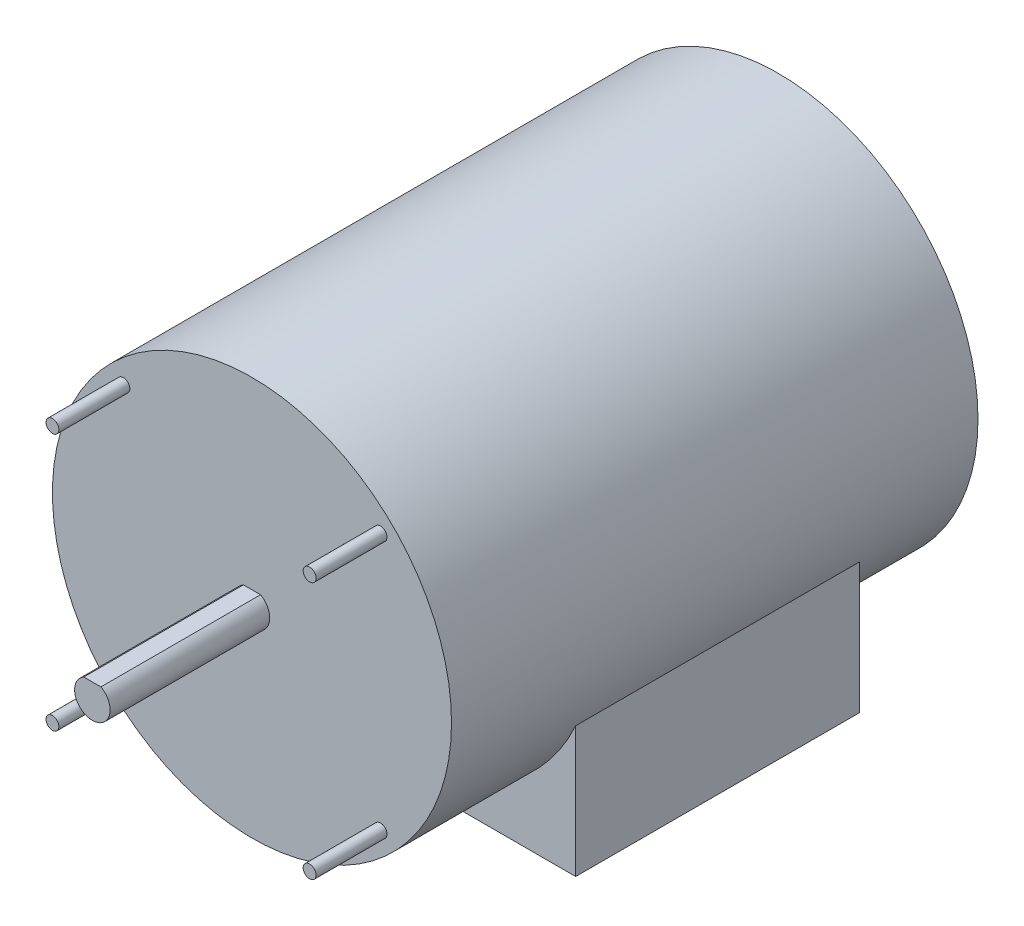
from build123d import *

# Parameters (mm, degrees)
SKETCH1_R           = 71.4375
BOSS_EXTRUDE1_DEPTH = 188.4934
SKETCH2_R           = 2.308225
BOSS_EXTRUDE2_DEPTH = 25.4
BOSS_EXTRUDE3_DEPTH = 57.15
SKETCH4_W           = 130.175
SKETCH4_H           = 101.6
SKETCH4_R           = 4.3688
BOSS_EXTRUDE4_DEPTH = 76.2


with BuildPart() as part:
    # Sketch1 → Boss-Extrude1 (new body)
    with BuildSketch(Plane.XY):
        Circle(SKETCH1_R)
    extrude(amount=BOSS_EXTRUDE1_DEPTH)

    # Sketch2 → Boss-Extrude2 (add)
    with BuildSketch(Plane.XY.offset(188.4934)):
        with Locations((-46.0375, 46.0375)):
            Circle(SKETCH2_R)
        with Locations((-46.0375, -46.0375)):
            Circle(SKETCH2_R)
        with Locations((46.0375, -46.0375)):
            Circle(SKETCH2_R)
        with Locations((46.0375, 46.0375)):
            Circle(SKETCH2_R)
    extrude(amount=BOSS_EXTRUDE2_DEPTH)

    # Sketch3 → Boss-Extrude3 (add)
    with BuildSketch(Plane.XY.offset(188.4934)):
        with BuildLine():
            Line((-3.062675504, 5.5626), (3.062675504, 5.5626))
            ThreePointArc((3.062675504, 5.5626), (0, -6.35), (-3.062675504, 5.5626))
        make_face()
    extrude(amount=BOSS_EXTRUDE3_DEPTH)

    # Sketch4 → Boss-Extrude4 (add)
    with BuildSketch(Plane(origin=(0, 0, 0), x_dir=(1, 0, 0), z_dir=(0, 1, 0))):
        with Locations((0, -86.8934)):
            Rectangle(SKETCH4_W, SKETCH4_H)
        with Locations((-53.975, -121.8184)):
            Circle(SKETCH4_R, mode=Mode.SUBTRACT)
        with Locations((53.975, -121.8184)):
            Circle(SKETCH4_R, mode=Mode.SUBTRACT)
        with Locations((-53.975, -51.9684)):
            Circle(SKETCH4_R, mode=Mode.SUBTRACT)
        with Locations((53.975, -51.9684)):
            Circle(SKETCH4_R, mode=Mode.SUBTRACT)
    extrude(amount=-BOSS_EXTRUDE4_DEPTH)


solid = part.part
